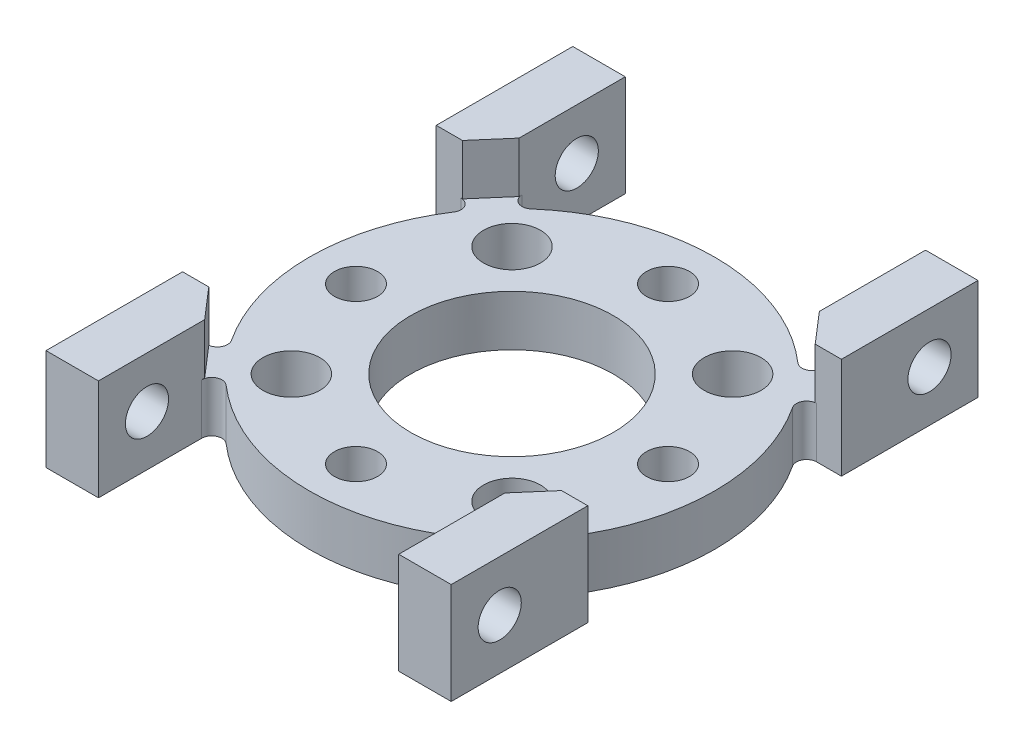
from build123d import *

# Parameters (mm, degrees)
SKETCH1_W                    = 25.4
SKETCH1_H                    = 33.02
BOSS_EXTRUDE1_DEPTH          = 6.35
CUT_EXTRUDE1_REACH           = 37.943
SKETCH2_W                    = 18.8214
SKETCH2_H                    = 3.175
SKETCH3_W                    = 15.9004
SKETCH3_H                    = 3.175
CUT_EXTRUDE2_DEPTH           = 31.952586322
CUT_EXTRUDE3_REACH           = 23.07
SKETCH4_R                    = 6.35
CUT_EXTRUDE4_REACH           = 23.07
CUT_EXTRUDE5_REACH           = 23.07
CUT_EXTRUDE6_DEPTH           = 3.175
F_6_32_TAPPED_HOLE1_D        = 2.7051
F_28_0_1405_DIAMETER_HOLE1_D = 3.5687
F_6_32_TAPPED_HOLE2_REACH    = 32.953
F_6_32_TAPPED_HOLE2_BORE_R   = 1.35255


with BuildPart() as part:
    # Sketch1 → Boss-Extrude1 (new body)
    with BuildSketch(Plane(origin=(0, 0, 0), x_dir=(1, 0, 0), z_dir=(0, 1, 0))):
        Rectangle(SKETCH1_W, SKETCH1_H)
    extrude(amount=BOSS_EXTRUDE1_DEPTH)

    # Sketch2 → Cut-Extrude1 (cut, up to next)
    with BuildSketch(Plane.XY.offset(16.51), mode=Mode.PRIVATE) as cut_extrude1_sk1:
        with Locations((0, 4.7625)):
            Rectangle(SKETCH2_W, SKETCH2_H)
    cut_extrude1_tool1 = extrude(cut_extrude1_sk1.sketch, amount=-CUT_EXTRUDE1_REACH, mode=Mode.PRIVATE) & part.part
    add(cut_extrude1_tool1.solids().sort_by_distance((0, 4.7625, 16.51))[0], mode=Mode.SUBTRACT)

    # Sketch3 → Cut-Extrude2 (cut, through all)
    with BuildSketch(Plane(origin=(12.7, 0, 0), x_dir=(0, 0, -1), z_dir=(1, 0, 0))):
        with Locations((0, 4.7625)):
            Rectangle(SKETCH3_W, SKETCH3_H)
    extrude(amount=-CUT_EXTRUDE2_DEPTH, mode=Mode.SUBTRACT)

    # Sketch4 → Cut-Extrude3 (cut, up to next)
    with BuildSketch(Plane(origin=(0, 3.175, 0), x_dir=(1, 0, 0), z_dir=(0, 1, 0)), mode=Mode.PRIVATE) as cut_extrude3_sk1:
        with Locations(Location((0, 0, 0), (0, 0, 270))):
            Circle(SKETCH4_R)
    cut_extrude3_tool1 = extrude(cut_extrude3_sk1.sketch, amount=-CUT_EXTRUDE3_REACH, mode=Mode.PRIVATE) & part.part
    add(cut_extrude3_tool1.solids().sort_by_distance((0, 3.175, 0))[0], mode=Mode.SUBTRACT)

    # Sketch5 → Cut-Extrude4 (cut, up to next)
    with BuildSketch(Plane(origin=(0, 3.175, 0), x_dir=(-1, 0, 0), z_dir=(0, 1, 0)), mode=Mode.PRIVATE) as cut_extrude4_sk1:
        with BuildLine():
            Line((11.149442765, -7.9502), (12.7, -7.9502))
            Line((12.7, -7.9502), (12.7, 0))
            ThreePointArc((12.7, 0), (12.168507815, -3.635576648), (10.618516919, -6.966857143))
            ThreePointArc((10.618516919, -6.966857143), (10.590684, -7.616884675), (11.149442765, -7.9502))
        make_face()
    cut_extrude4_tool1 = extrude(cut_extrude4_sk1.sketch, amount=-CUT_EXTRUDE4_REACH, mode=Mode.PRIVATE) & part.part
    # Sketch5 → Cut-Extrude4 (cut, up to next)
    with BuildSketch(Plane(origin=(0, 3.175, 0), x_dir=(-1, 0, 0), z_dir=(0, 1, 0)), mode=Mode.PRIVATE) as cut_extrude4_sk2:
        with BuildLine():
            ThreePointArc((10.618516919, 6.966857143), (12.168507815, 3.635576648), (12.7, 0))
            Line((12.7, 0), (12.7, 7.9502))
            Line((12.7, 7.9502), (11.149442765, 7.9502))
            ThreePointArc((11.149442765, 7.9502), (10.590684, 7.616884675), (10.618516919, 6.966857143))
        make_face()
    cut_extrude4_tool2 = extrude(cut_extrude4_sk2.sketch, amount=-CUT_EXTRUDE4_REACH, mode=Mode.PRIVATE) & part.part
    # Sketch5 → Cut-Extrude4 (cut, up to next)
    with BuildSketch(Plane(origin=(0, 3.175, 0), x_dir=(-1, 0, 0), z_dir=(0, 1, 0)), mode=Mode.PRIVATE) as cut_extrude4_sk3:
        with BuildLine():
            ThreePointArc((-10.618516919, -6.966857143), (-12.168507815, -3.635576648), (-12.7, 0))
            Line((-12.7, 0), (-12.7, -7.9502))
            Line((-12.7, -7.9502), (-11.149442765, -7.9502))
            ThreePointArc((-11.149442765, -7.9502), (-10.590684, -7.616884675), (-10.618516919, -6.966857143))
        make_face()
    cut_extrude4_tool3 = extrude(cut_extrude4_sk3.sketch, amount=-CUT_EXTRUDE4_REACH, mode=Mode.PRIVATE) & part.part
    # Sketch5 → Cut-Extrude4 (cut, up to next)
    with BuildSketch(Plane(origin=(0, 3.175, 0), x_dir=(-1, 0, 0), z_dir=(0, 1, 0)), mode=Mode.PRIVATE) as cut_extrude4_sk4:
        with BuildLine():
            Line((-12.7, 7.9502), (-12.7, 0))
            ThreePointArc((-12.7, 0), (-12.168507815, 3.635576648), (-10.618516919, 6.966857143))
            ThreePointArc((-10.618516919, 6.966857143), (-10.590684, 7.616884675), (-11.149442765, 7.9502))
            Line((-11.149442765, 7.9502), (-12.7, 7.9502))
        make_face()
    cut_extrude4_tool4 = extrude(cut_extrude4_sk4.sketch, amount=-CUT_EXTRUDE4_REACH, mode=Mode.PRIVATE) & part.part
    add(cut_extrude4_tool1.solids().sort_by_distance((-11.953453, 3.175, -5.924274))[0], mode=Mode.SUBTRACT)
    add(cut_extrude4_tool2.solids().sort_by_distance((-11.953453, 3.175, 5.924274))[0], mode=Mode.SUBTRACT)
    add(cut_extrude4_tool3.solids().sort_by_distance((11.953453, 3.175, -5.924274))[0], mode=Mode.SUBTRACT)
    add(cut_extrude4_tool4.solids().sort_by_distance((11.953453, 3.175, 5.924274))[0], mode=Mode.SUBTRACT)

    # Sketch6 → Cut-Extrude5 (cut, up to next)
    with BuildSketch(Plane(origin=(0, 3.175, 0), x_dir=(1, 0, 0), z_dir=(0, 1, 0)), mode=Mode.PRIVATE) as cut_extrude5_sk1:
        with BuildLine():
            Line((-9.4107, -10.040384181), (-9.4107, -16.51))
            Line((-9.4107, -16.51), (9.4107, -16.51))
            Line((9.4107, -16.51), (9.4107, -10.040384181))
            ThreePointArc((9.4107, -10.040384181), (9.038249564, -9.462203651), (8.357809524, -9.562270649))
            ThreePointArc((8.357809524, -9.562270649), (0, -12.7), (-8.357809524, -9.562270649))
            ThreePointArc((-8.357809524, -9.562270649), (-9.038249564, -9.462203651), (-9.4107, -10.040384181))
        make_face()
    cut_extrude5_tool1 = extrude(cut_extrude5_sk1.sketch, amount=-CUT_EXTRUDE5_REACH, mode=Mode.PRIVATE) & part.part
    # Sketch6 → Cut-Extrude5 (cut, up to next)
    with BuildSketch(Plane(origin=(0, 3.175, 0), x_dir=(1, 0, 0), z_dir=(0, 1, 0)), mode=Mode.PRIVATE) as cut_extrude5_sk2:
        with BuildLine():
            Line((9.4107, 16.51), (9.4107, 10.040384181))
            ThreePointArc((9.4107, 10.040384181), (9.038249564, 9.462203651), (8.357809524, 9.562270649))
            ThreePointArc((8.357809524, 9.562270649), (0, 12.7), (-8.357809524, 9.562270649))
            ThreePointArc((-8.357809524, 9.562270649), (-9.038249564, 9.462203651), (-9.4107, 10.040384181))
            Line((-9.4107, 10.040384181), (-9.4107, 16.51))
            Line((-9.4107, 16.51), (9.4107, 16.51))
        make_face()
    cut_extrude5_tool2 = extrude(cut_extrude5_sk2.sketch, amount=-CUT_EXTRUDE5_REACH, mode=Mode.PRIVATE) & part.part
    add(cut_extrude5_tool1.solids().sort_by_distance((0, 3.175, 13.865951))[0], mode=Mode.SUBTRACT)
    add(cut_extrude5_tool2.solids().sort_by_distance((0, 3.175, -13.865951))[0], mode=Mode.SUBTRACT)

    # Sketch7 → Cut-Extrude6 (cut)
    with BuildSketch(Plane(origin=(0, 6.35, 0), x_dir=(1, 0, 0), z_dir=(0, 1, 0))):
        Polygon((-11.05535, 7.9502), (-9.4107, 9.8552), (-9.4107, 7.9502), align=None)
        Polygon((-11.05535, -7.9502), (-9.4107, -9.8552), (-9.4107, -7.9502), align=None)
        Polygon((9.4107, -9.8552), (11.05535, -7.9502), (9.4107, -7.9502), align=None)
        Polygon((9.4107, 9.8552), (11.05535, 7.9502), (9.4107, 7.9502), align=None)
    extrude(amount=-CUT_EXTRUDE6_DEPTH, mode=Mode.SUBTRACT)

    # #6-32 Tapped Hole1 (through all)
    with Locations(Plane(origin=(0, 3.175, 0), x_dir=(-1, 0, 0), z_dir=(0, 1, 0))):
        with Locations((0, -9.779), (-9.779, 0), (0, 9.779), (9.779, 0)):
            Hole(F_6_32_TAPPED_HOLE1_D / 2)

    # #28 (0.1405) Diameter Hole1 (through all)
    with Locations(Plane(origin=(0, 3.175, 0), x_dir=(-1, 0, 0), z_dir=(0, 1, 0))):
        with Locations((6.914797213, -6.914797213), (-6.914797213, -6.914797213), (-6.914797213, 6.914797213), (6.914797213, 6.914797213)):
            Hole(F_28_0_1405_DIAMETER_HOLE1_D / 2)

    # #6-32 Tapped Hole2 bore → #6-32 Tapped Hole2 (cut, up to next)
    with BuildSketch(Plane(origin=(12.7, 0, 0), x_dir=(0, 0, -1), z_dir=(1, 0, 0)), mode=Mode.PRIVATE) as f_6_32_tapped_hole2_sk1:
        with Locations((-13.470384182, 3.175)):
            Circle(F_6_32_TAPPED_HOLE2_BORE_R)
    f_6_32_tapped_hole2_tool1 = extrude(f_6_32_tapped_hole2_sk1.sketch, amount=-F_6_32_TAPPED_HOLE2_REACH, mode=Mode.PRIVATE) & part.part
    # #6-32 Tapped Hole2 bore → #6-32 Tapped Hole2 (cut, up to next)
    with BuildSketch(Plane(origin=(12.7, 0, 0), x_dir=(0, 0, -1), z_dir=(1, 0, 0)), mode=Mode.PRIVATE) as f_6_32_tapped_hole2_sk2:
        with Locations((13.470384182, 3.175)):
            Circle(F_6_32_TAPPED_HOLE2_BORE_R)
    f_6_32_tapped_hole2_tool2 = extrude(f_6_32_tapped_hole2_sk2.sketch, amount=-F_6_32_TAPPED_HOLE2_REACH, mode=Mode.PRIVATE) & part.part
    f_6_32_tapped_hole2_1 = f_6_32_tapped_hole2_tool1.solids().sort_by_distance((12.7, 3.175, 13.470384))[0]
    add(f_6_32_tapped_hole2_1, mode=Mode.SUBTRACT)
    f_6_32_tapped_hole2_2 = f_6_32_tapped_hole2_tool2.solids().sort_by_distance((12.7, 3.175, -13.470384))[0]
    add(f_6_32_tapped_hole2_2, mode=Mode.SUBTRACT)
    f_6_32_tapped_hole2 = f_6_32_tapped_hole2_1 + f_6_32_tapped_hole2_2  # #6-32 Tapped Hole2 as one shape, for the pattern or mirror that repeats it

    # Mirror1: #6-32 Tapped Hole2 across plane
    add(f_6_32_tapped_hole2.mirror(Plane(origin=(0, 0, 0), x_dir=(0, 0, 1), z_dir=(1, 0, 0))), mode=Mode.SUBTRACT)


solid = part.part
